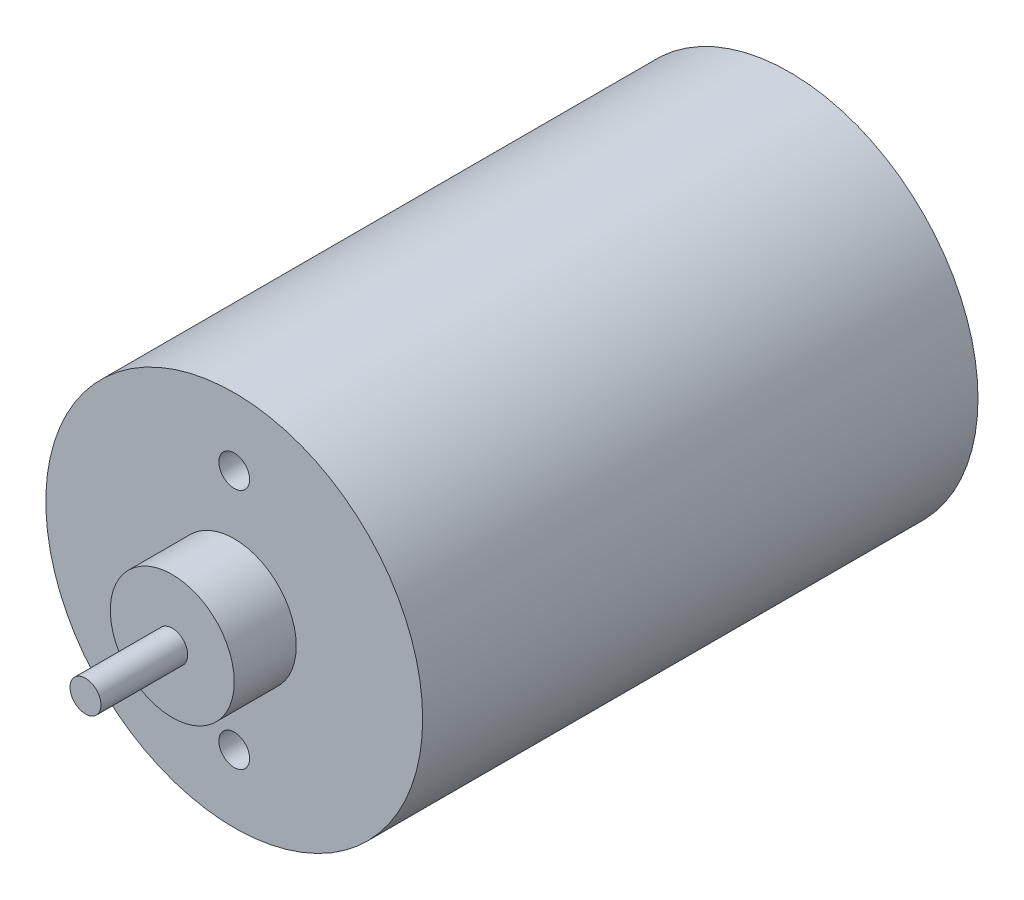
from build123d import *

# Parameters (mm, degrees)
SKETCH1_R           = 19.304
BOSS_EXTRUDE1_DEPTH = 56.896
SKETCH2_R           = 6.35
BOSS_EXTRUDE2_DEPTH = 6.35
SKETCH3_R           = 1.575
CUT_EXTRUDE1_DEPTH  = 3.175
SKETCH4_R           = 1.5875
BOSS_EXTRUDE3_DEPTH = 8.89


with BuildPart() as part:
    # Sketch1 → Boss-Extrude1 (new body)
    with BuildSketch(Plane.XY):
        Circle(SKETCH1_R)
    extrude(amount=BOSS_EXTRUDE1_DEPTH)

    # Sketch2 → Boss-Extrude2 (add)
    with BuildSketch(Plane.XY.offset(56.896)):
        Circle(SKETCH2_R)
    extrude(amount=BOSS_EXTRUDE2_DEPTH)

    # Sketch3 → Cut-Extrude1 (cut)
    with BuildSketch(Plane.XY.offset(56.896)):
        with Locations((0, 12.3825)):
            Circle(SKETCH3_R)
        with Locations((0, -12.3825)):
            Circle(SKETCH3_R)
    extrude(amount=-CUT_EXTRUDE1_DEPTH, mode=Mode.SUBTRACT)

    # Sketch4 → Boss-Extrude3 (add)
    with BuildSketch(Plane.XY.offset(63.246)):
        Circle(SKETCH4_R)
    extrude(amount=BOSS_EXTRUDE3_DEPTH)


solid = part.part
